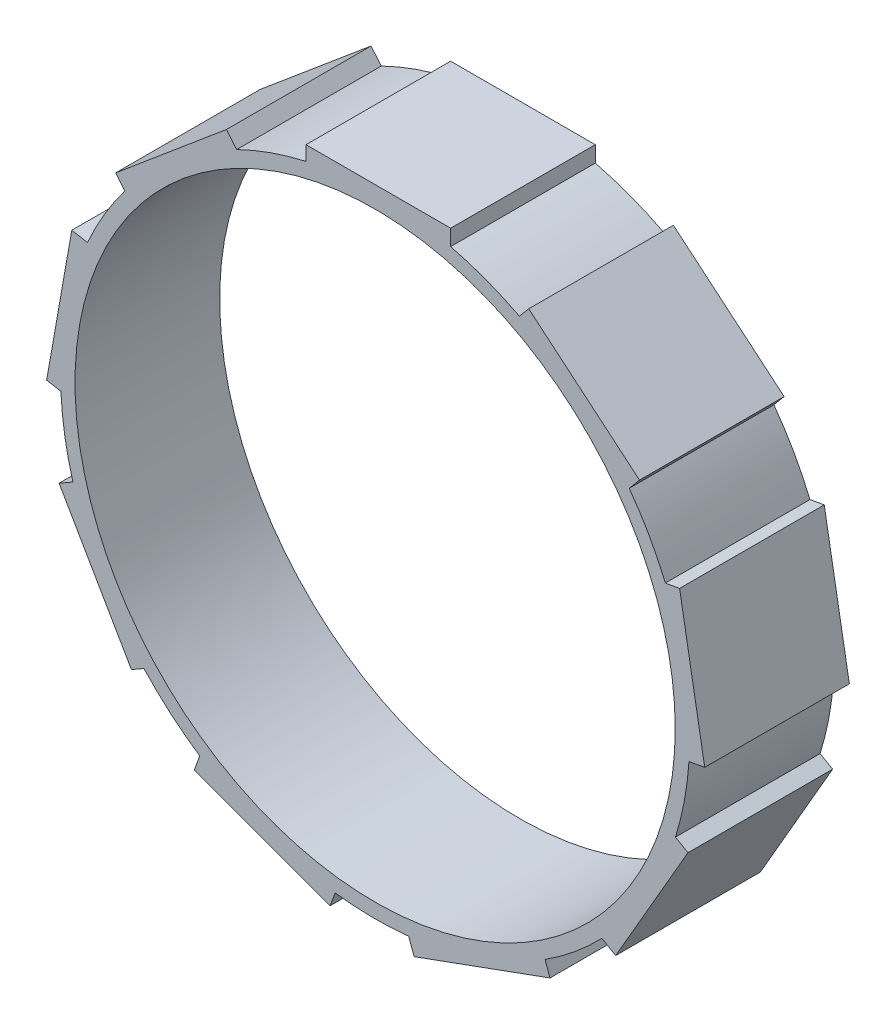
from build123d import *

# Parameters (mm, degrees)
CROQUIS1_R              = 20.75
SALIENTE_EXTRUIR1_DEPTH = 10


with BuildPart() as part:
    # Croquis1 → Saliente-Extruir1 (new body)
    with BuildSketch(Plane.XY):
        with BuildLine():
            ThreePointArc((-4.78021978, 21.218199708), (-0.225829084, -21.748827583), (5.21978022, 21.114364647))
            Line((5.21978022, 21.114364647), (5.21978022, 22.218199708))
            Line((5.21978022, 22.218199708), (-4.78021978, 22.218199708))
            Line((-4.78021978, 22.218199708), (-4.78021978, 21.218199708))
        make_face()
        Circle(CROQUIS1_R, mode=Mode.SUBTRACT)
        with BuildLine():
            ThreePointArc((-17.300656672, 13.181417933), (-13.806881781, 16.805728651), (-9.57346835, 19.529751759))
            Line((-9.57346835, 19.529751759), (-10.28299985, 20.375338473))
            Line((-10.28299985, 20.375338473), (-17.943444281, 13.947462376))
            Line((-17.943444281, 13.947462376), (-17.300656672, 13.181417933))
        make_face()
        with BuildLine():
            Line((18.280167114, 13.664918372), (10.619722682, 20.092794469))
            Line((10.619722682, 20.092794469), (9.976935073, 19.326750026))
            ThreePointArc((9.976935073, 19.326750026), (14.15287201, 16.515408377), (17.570635613, 12.819331657))
            Line((17.570635613, 12.819331657), (18.280167114, 13.664918372))
        make_face()
        with BuildLine():
            ThreePointArc((-21.725924031, -1.023095788), (-21.379199214, 3.999042508), (-19.887184682, 8.806950973))
            Line((-19.887184682, 8.806950973), (-20.974250008, 8.99862992))
            Line((-20.974250008, 8.99862992), (-22.710731784, -0.84944761))
            Line((-22.710731784, -0.84944761), (-21.725924031, -1.023095788))
        make_face()
        with BuildLine():
            Line((21.050578877, 8.565747391), (20.065771124, 8.392099213))
            ThreePointArc((20.065771124, 8.392099213), (21.457628831, 3.554246044), (21.699995328, -1.474009086))
            Line((21.699995328, -1.474009086), (22.787060653, -1.282330139))
            Line((22.787060653, -1.282330139), (21.050578877, 8.565747391))
        make_face()
        with BuildLine():
            Line((21.631635264, -6.969308089), (20.76560986, -6.469308089))
            ThreePointArc((20.76560986, -6.469308089), (18.722122647, -11.069987515), (15.675686059, -15.077644596))
            Line((15.675686059, -15.077644596), (16.631635264, -15.629562127))
            Line((16.631635264, -15.629562127), (21.631635264, -6.969308089))
        make_face()
        with BuildLine():
            ThreePointArc((-15.98539008, -14.748891619), (-18.947951731, -10.678840068), (-20.895466279, -6.036720051))
            Line((-20.895466279, -6.036720051), (-21.851415483, -6.588637582))
            Line((-21.851415483, -6.588637582), (-16.851415483, -15.248891619))
            Line((-16.851415483, -15.248891619), (-15.98539008, -14.748891619))
        make_face()
        with BuildLine():
            Line((-3.107134595, -22.513209767), (-2.765114452, -21.573517146))
            ThreePointArc((-2.765114452, -21.573517146), (-7.65074705, -20.359974695), (-12.126526978, -18.055742673))
            Line((-12.126526978, -18.055742673), (-12.504060803, -19.093008334))
            Line((-12.504060803, -19.093008334), (-3.107134595, -22.513209767))
        make_face()
        with BuildLine():
            Line((12.091009102, -19.243346858), (11.748988958, -18.303654238))
            ThreePointArc((11.748988958, -18.303654238), (7.226327204, -20.514450886), (2.316549068, -21.626282631))
            Line((2.316549068, -21.626282631), (2.694082894, -22.663548292))
            Line((2.694082894, -22.663548292), (12.091009102, -19.243346858))
        make_face()
    extrude(amount=SALIENTE_EXTRUIR1_DEPTH)


solid = part.part
